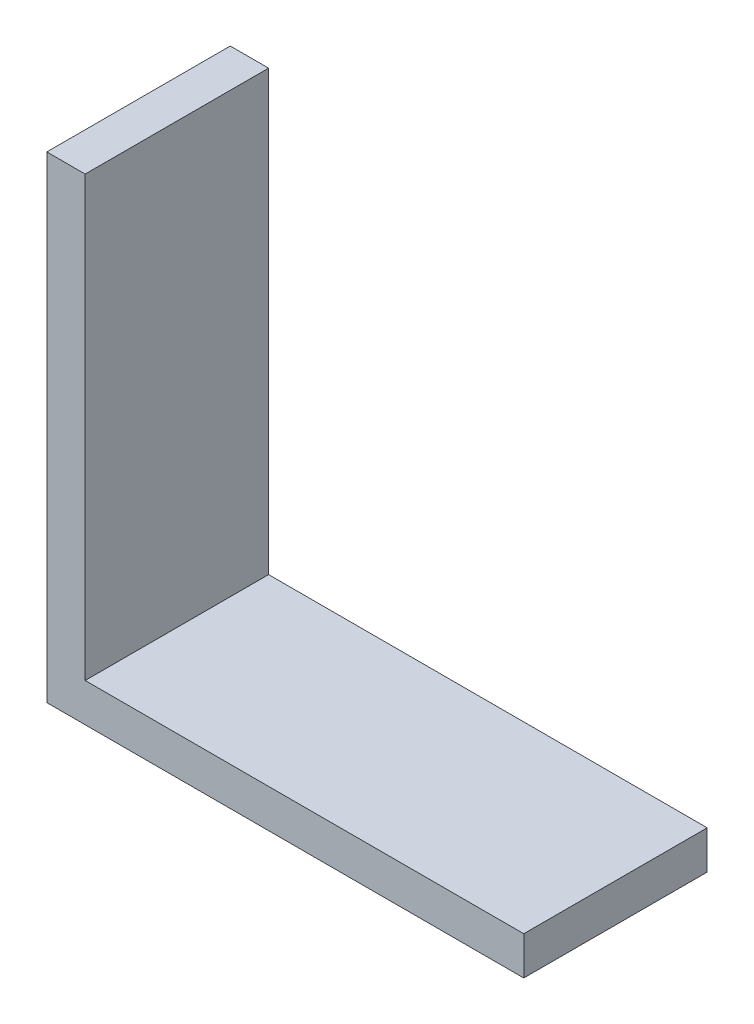
from build123d import *

# Parameters (mm, degrees)
SKETCH1_W           = 30.95625
SKETCH1_H           = 11.90625
BOSS_EXTRUDE1_DEPTH = 2.4892
SKETCH2_W           = 2.4892
SKETCH2_H           = 11.90625
BOSS_EXTRUDE2_DEPTH = 30.95625


with BuildPart() as part:
    # Sketch1 → Boss-Extrude1 (new body)
    with BuildSketch(Plane(origin=(0, 0, 0), x_dir=(1, 0, 0), z_dir=(0, 1, 0))):
        Rectangle(SKETCH1_W, SKETCH1_H)
    extrude(amount=BOSS_EXTRUDE1_DEPTH)

    # Sketch2 → Boss-Extrude2 (add)
    with BuildSketch(Plane(origin=(0, 0, 0), x_dir=(1, 0, 0), z_dir=(0, 1, 0))):
        with Locations((-14.233525, 0)):
            Rectangle(SKETCH2_W, SKETCH2_H)
    extrude(amount=BOSS_EXTRUDE2_DEPTH)


solid = part.part
